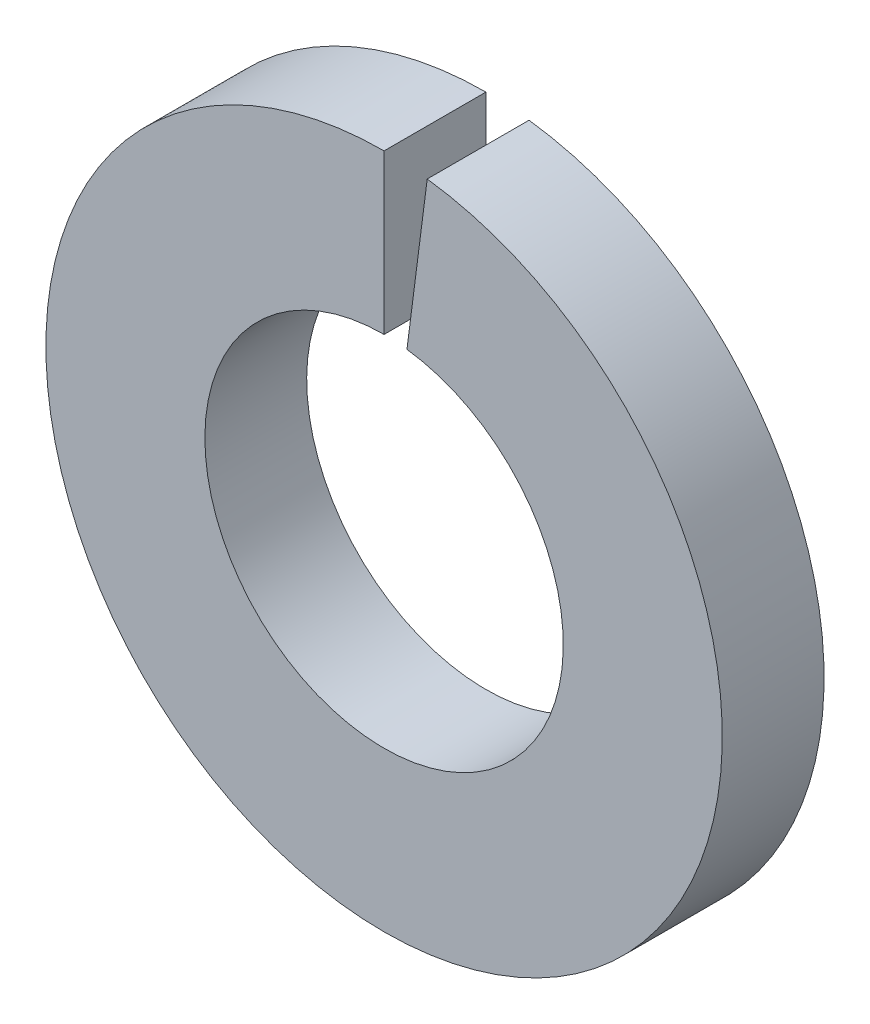
from build123d import *

# Parameters (mm, degrees)
SKETCH1_R      = 6.1595
SKETCH1_R_2    = 3.2639
EXTRUDE1_DEPTH = 1.8542
EXTRUDE2_DEPTH = 1.8542


with BuildPart() as part:
    # Sketch1 → Extrude1 (new body)
    with BuildSketch(Plane.XY):
        Circle(SKETCH1_R)
        Circle(SKETCH1_R_2, mode=Mode.SUBTRACT)
    extrude(amount=EXTRUDE1_DEPTH)

    # Sketch2 → Extrude2 (cut)
    with BuildSketch(Plane.XY.offset(1.8542)):
        with BuildLine():
            Line((0, 0), (0, 6.1595))
            ThreePointArc((0, 6.1595), (0.393778969, 6.146899899), (0.785946881, 6.109151148))
            Line((0.785946881, 6.109151148), (0, 0))
        make_face()
    extrude(amount=-EXTRUDE2_DEPTH, mode=Mode.SUBTRACT)


solid = part.part
